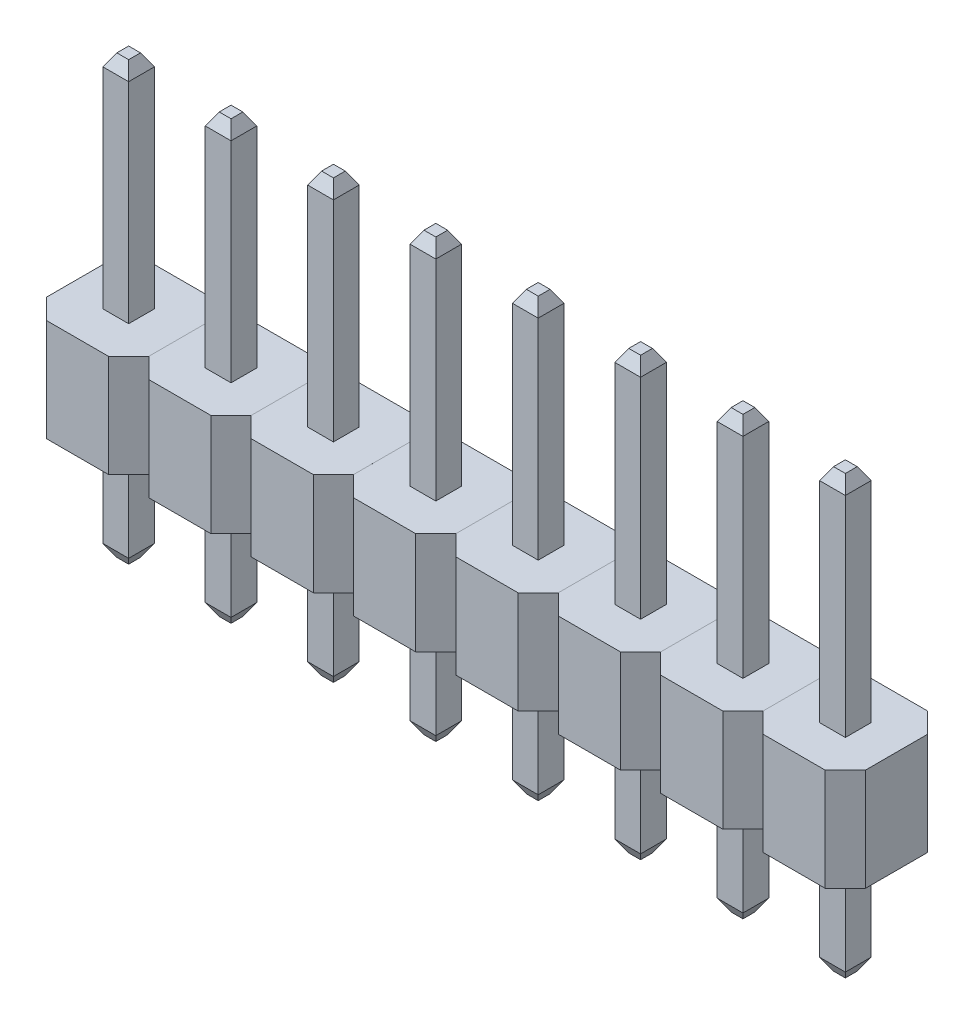
from build123d import *

# Parameters (mm, degrees)
SKETCH1_W             = 2.54
SKETCH1_H             = 2.54
BOSS_EXTRUDE1_DEPTH   = 2.54
CHAMFER1_SIZE         = 0.5
SKETCH3_W             = 0.64
SKETCH3_H             = 0.64
CHAMFER2_SIZE         = 0.3
CHAMFER2_SIZE2        = 0.173205081
CHAMFER2_PART_2_SIZE  = 0.3
CHAMFER2_PART_2_SIZE2 = 0.173205081
CHAMFER2_PART_3_SIZE  = 0.3
CHAMFER2_PART_3_SIZE2 = 0.173205081
CHAMFER2_PART_4_SIZE  = 0.3
CHAMFER2_PART_4_SIZE2 = 0.173205081
LPATTERN6_COUNT       = 8
LPATTERN6_PITCH       = 2.54


with BuildPart() as part:
    # Sketch1 → Boss-Extrude1 (new body)
    with BuildSketch(Plane(origin=(0, 0, 0), x_dir=(1, 0, 0), z_dir=(0, 1, 0))):
        Rectangle(SKETCH1_W, SKETCH1_H)
    extrude(amount=BOSS_EXTRUDE1_DEPTH)

    # Chamfer1
    chamfer1_edges = [part.edges().sort_by_distance(p)[0] for p in [
        (1.27, 1.27, 1.27),
        (-1.27, 1.27, 1.27),
        (-1.27, 1.27, -1.27),
        (1.27, 1.27, -1.27),
    ]]
    chamfer(chamfer1_edges, length=CHAMFER1_SIZE)


with BuildPart() as body_2:
    # Sweep1: sweep along a path in Sketch2
    with BuildLine(Plane(origin=(0, 0, 0), x_dir=(0, 0, -1), z_dir=(1, 0, 0))) as sweep1_path:
        Line((0, 8.04), (0, -2.8))
    # Sketch3 → Sweep1 (sweep)
    with BuildSketch(Plane(origin=(0, 0, 0), x_dir=(1, 0, 0), z_dir=(0, 1, 0))):
        Rectangle(SKETCH3_W, SKETCH3_H)
    sweep(path=sweep1_path.line)

    # Chamfer2
    chamfer2_edges = [body_2.edges().sort_by_distance(p)[0] for p in [
        (0, -2.8, -0.32),
        (0, 8.04, -0.32),
    ]]
    chamfer2_side = [body_2.faces().sort_by_distance(p)[0] for p in [
        (0, 2.62, -0.32),
    ]]
    chamfer(chamfer2_edges, length=CHAMFER2_SIZE, length2=CHAMFER2_SIZE2, reference=chamfer2_side[0])

    # Chamfer2 part 2
    chamfer2_part_2_edges = [body_2.edges().sort_by_distance(p)[0] for p in [
        (-0.32, -2.8, 0),
        (-0.32, 8.04, 0),
    ]]
    chamfer2_part_2_side = [body_2.faces().sort_by_distance(p)[0] for p in [
        (-0.32, 2.62, 0),
    ]]
    chamfer(chamfer2_part_2_edges, length=CHAMFER2_PART_2_SIZE, length2=CHAMFER2_PART_2_SIZE2, reference=chamfer2_part_2_side[0])

    # Chamfer2 part 3
    chamfer2_part_3_edges = [body_2.edges().sort_by_distance(p)[0] for p in [
        (0, -2.8, 0.32),
        (0, 8.04, 0.32),
    ]]
    chamfer2_part_3_side = [body_2.faces().sort_by_distance(p)[0] for p in [
        (0, 2.62, 0.32),
    ]]
    chamfer(chamfer2_part_3_edges, length=CHAMFER2_PART_3_SIZE, length2=CHAMFER2_PART_3_SIZE2, reference=chamfer2_part_3_side[0])

    # Chamfer2 part 4
    chamfer2_part_4_edges = [body_2.edges().sort_by_distance(p)[0] for p in [
        (0.32, 8.04, 0),
        (0.32, -2.8, 0),
    ]]
    chamfer2_part_4_side = [body_2.faces().sort_by_distance(p)[0] for p in [
        (0.32, 2.62, 0),
    ]]
    chamfer(chamfer2_part_4_edges, length=CHAMFER2_PART_4_SIZE, length2=CHAMFER2_PART_4_SIZE2, reference=chamfer2_part_4_side[0])


with BuildPart() as lpattern6_1:
    # LPattern6: pattern copy
    add(body_2.part.moved(Location(Vector(1, 0, 0) * (1 * LPATTERN6_PITCH))))


with BuildPart() as lpattern6_2:
    # LPattern6: pattern copy
    add(body_2.part.moved(Location(Vector(1, 0, 0) * (2 * LPATTERN6_PITCH))))


with BuildPart() as lpattern6_3:
    # LPattern6: pattern copy
    add(body_2.part.moved(Location(Vector(1, 0, 0) * (3 * LPATTERN6_PITCH))))


with BuildPart() as lpattern6_4:
    # LPattern6: pattern copy
    add(body_2.part.moved(Location(Vector(1, 0, 0) * (4 * LPATTERN6_PITCH))))


with BuildPart() as lpattern6_5:
    # LPattern6: pattern copy
    add(body_2.part.moved(Location(Vector(1, 0, 0) * (5 * LPATTERN6_PITCH))))


with BuildPart() as lpattern6_6:
    # LPattern6: pattern copy
    add(body_2.part.moved(Location(Vector(1, 0, 0) * (6 * LPATTERN6_PITCH))))


with BuildPart() as lpattern6_7:
    # LPattern6: pattern copy
    add(body_2.part.moved(Location(Vector(1, 0, 0) * (7 * LPATTERN6_PITCH))))


with BuildPart() as lpattern6_8:
    # LPattern6: pattern copy
    add(part.part.moved(Location(Vector(1, 0, 0) * (1 * LPATTERN6_PITCH))))


with BuildPart() as lpattern6_9:
    # LPattern6: pattern copy
    add(part.part.moved(Location(Vector(1, 0, 0) * (2 * LPATTERN6_PITCH))))


with BuildPart() as lpattern6_10:
    # LPattern6: pattern copy
    add(part.part.moved(Location(Vector(1, 0, 0) * (3 * LPATTERN6_PITCH))))


with BuildPart() as lpattern6_11:
    # LPattern6: pattern copy
    add(part.part.moved(Location(Vector(1, 0, 0) * (4 * LPATTERN6_PITCH))))


with BuildPart() as lpattern6_12:
    # LPattern6: pattern copy
    add(part.part.moved(Location(Vector(1, 0, 0) * (5 * LPATTERN6_PITCH))))


with BuildPart() as lpattern6_13:
    # LPattern6: pattern copy
    add(part.part.moved(Location(Vector(1, 0, 0) * (6 * LPATTERN6_PITCH))))


with BuildPart() as lpattern6_14:
    # LPattern6: pattern copy
    add(part.part.moved(Location(Vector(1, 0, 0) * (7 * LPATTERN6_PITCH))))


solid = Compound([part.part, body_2.part, lpattern6_1.part, lpattern6_2.part, lpattern6_3.part, lpattern6_4.part, lpattern6_5.part, lpattern6_6.part, lpattern6_7.part, lpattern6_8.part, lpattern6_9.part, lpattern6_10.part, lpattern6_11.part, lpattern6_12.part, lpattern6_13.part, lpattern6_14.part])
